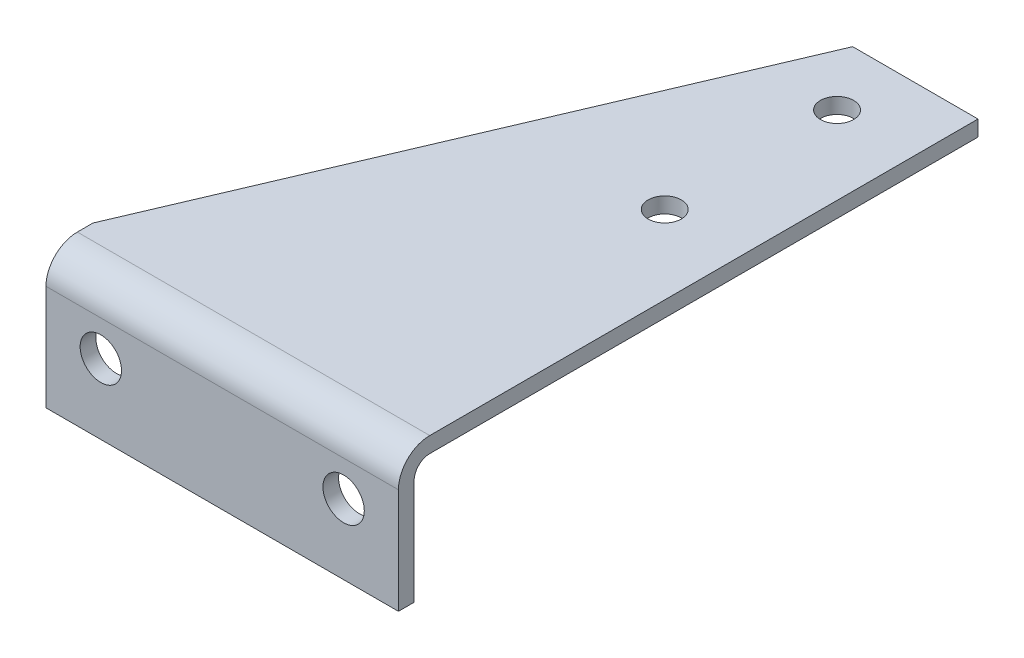
from build123d import *

# Parameters (mm, degrees)
BASE_EXTRUDE_DEPTH = 142.875
CUT_EXTRUDE1_REACH = 236.95
SKETCH2_R          = 8.382
CUT_EXTRUDE2_REACH = 57.372
SKETCH3_R          = 6.731


with BuildPart() as part:
    # Sketch1 → Base-Extrude (new body)
    with BuildSketch(Plane(origin=(0, 0, 0), x_dir=(0, 0, -1), z_dir=(1, 0, 0))):
        with BuildLine():
            Line((0, 0), (-222.25, 0))
            ThreePointArc((-222.25, 0), (-231.230256121, -3.719743879), (-234.95, -12.7))
            Line((-234.95, -12.7), (-234.95, -55.372))
            Line((-234.95, -55.372), (-228.6, -55.372))
            Line((-228.6, -55.372), (-228.6, -12.7))
            ThreePointArc((-228.6, -12.7), (-226.740128061, -8.209871939), (-222.25, -6.35))
            Line((-222.25, -6.35), (0, -6.35))
            Line((0, -6.35), (0, 0))
        make_face()
    extrude(amount=-BASE_EXTRUDE_DEPTH)

    # Sketch2 → Cut-Extrude1 (cut, up to next)
    with BuildSketch(Plane.XY.offset(234.95), mode=Mode.PRIVATE) as cut_extrude1_sk1:
        with Locations((-120.65, -26.9875)):
            Circle(SKETCH2_R)
    cut_extrude1_tool1 = extrude(cut_extrude1_sk1.sketch, amount=-CUT_EXTRUDE1_REACH, mode=Mode.PRIVATE) & part.part
    add(cut_extrude1_tool1.solids().sort_by_distance((-120.65, -26.9875, 234.95))[0], mode=Mode.SUBTRACT)
    # Sketch2 → Cut-Extrude1 (cut, up to next)
    with BuildSketch(Plane.XY.offset(234.95), mode=Mode.PRIVATE) as cut_extrude1_sk2:
        with Locations((-22.225, -26.9875)):
            Circle(SKETCH2_R)
    cut_extrude1_tool2 = extrude(cut_extrude1_sk2.sketch, amount=-CUT_EXTRUDE1_REACH, mode=Mode.PRIVATE) & part.part
    add(cut_extrude1_tool2.solids().sort_by_distance((-22.225, -26.9875, 234.95))[0], mode=Mode.SUBTRACT)

    # Sketch3 → Cut-Extrude2 (cut, up to next)
    with BuildSketch(Plane(origin=(0, 0, 0), x_dir=(-1, 0, 0), z_dir=(0, 1, 0)), mode=Mode.PRIVATE) as cut_extrude2_sk1:
        with Locations((31.75, 95.25)):
            Circle(SKETCH3_R)
    cut_extrude2_tool1 = extrude(cut_extrude2_sk1.sketch, amount=-CUT_EXTRUDE2_REACH, mode=Mode.PRIVATE) & part.part
    add(cut_extrude2_tool1.solids().sort_by_distance((-31.75, 0, 95.25))[0], mode=Mode.SUBTRACT)
    # Sketch3 → Cut-Extrude2 (cut, up to next)
    with BuildSketch(Plane(origin=(0, 0, 0), x_dir=(-1, 0, 0), z_dir=(0, 1, 0)), mode=Mode.PRIVATE) as cut_extrude2_sk2:
        with Locations((31.75, 25.4)):
            Circle(SKETCH3_R)
    cut_extrude2_tool2 = extrude(cut_extrude2_sk2.sketch, amount=-CUT_EXTRUDE2_REACH, mode=Mode.PRIVATE) & part.part
    add(cut_extrude2_tool2.solids().sort_by_distance((-31.75, 0, 25.4))[0], mode=Mode.SUBTRACT)
    # Sketch3 → Cut-Extrude2 (cut, up to next)
    with BuildSketch(Plane(origin=(0, 0, 0), x_dir=(-1, 0, 0), z_dir=(0, 1, 0)), mode=Mode.PRIVATE) as cut_extrude2_sk3:
        Polygon((142.875, 215.9), (50.8, 0), (142.875, 0), align=None)
    cut_extrude2_tool3 = extrude(cut_extrude2_sk3.sketch, amount=-CUT_EXTRUDE2_REACH, mode=Mode.PRIVATE) & part.part
    add(cut_extrude2_tool3.solids().sort_by_distance((-112.183333, 0, 71.966667))[0], mode=Mode.SUBTRACT)


solid = part.part
